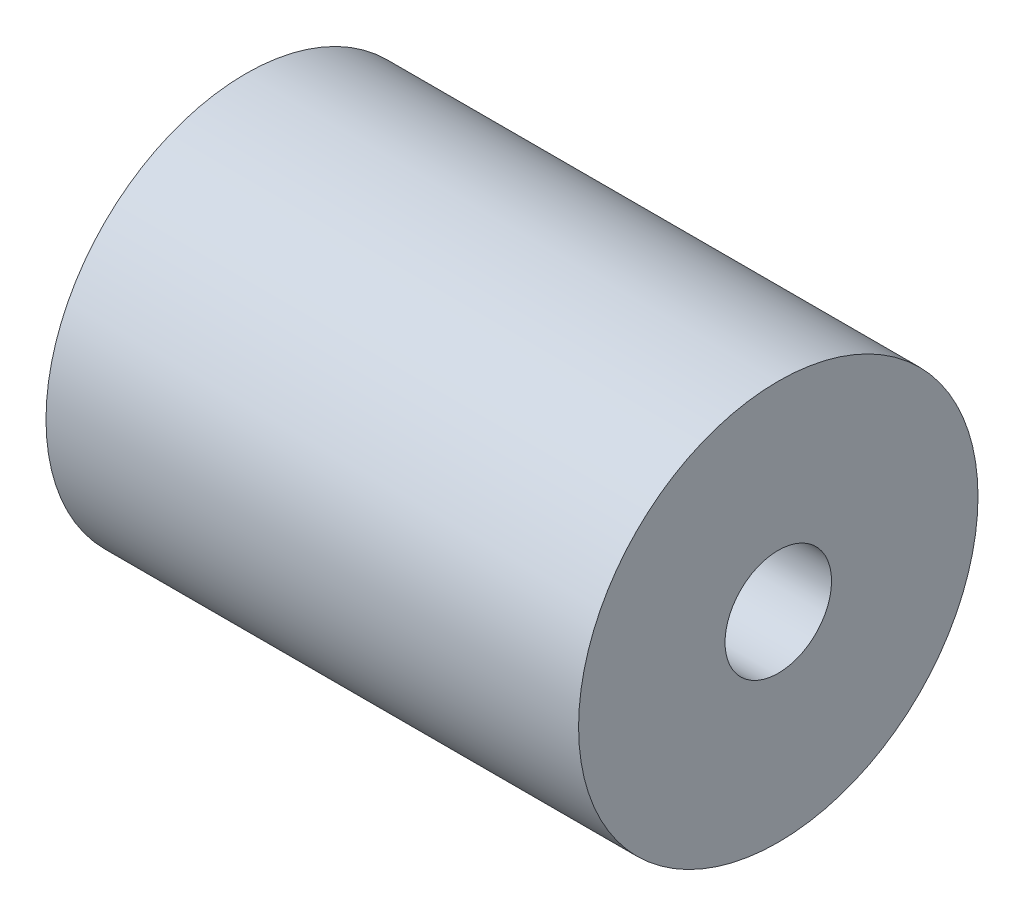
from build123d import *

# Parameters (mm, degrees)
SKETCH2_R           = 7.5
SKETCH2_R_2         = 2
BOSS_EXTRUDE1_DEPTH = 20


with BuildPart() as part:
    # Sketch2 → Boss-Extrude1 (new body)
    with BuildSketch(Plane(origin=(0, 0, 0), x_dir=(0, 0, -1), z_dir=(1, 0, 0))):
        Circle(SKETCH2_R)
        Circle(SKETCH2_R_2, mode=Mode.SUBTRACT)
    extrude(amount=BOSS_EXTRUDE1_DEPTH)


solid = part.part
